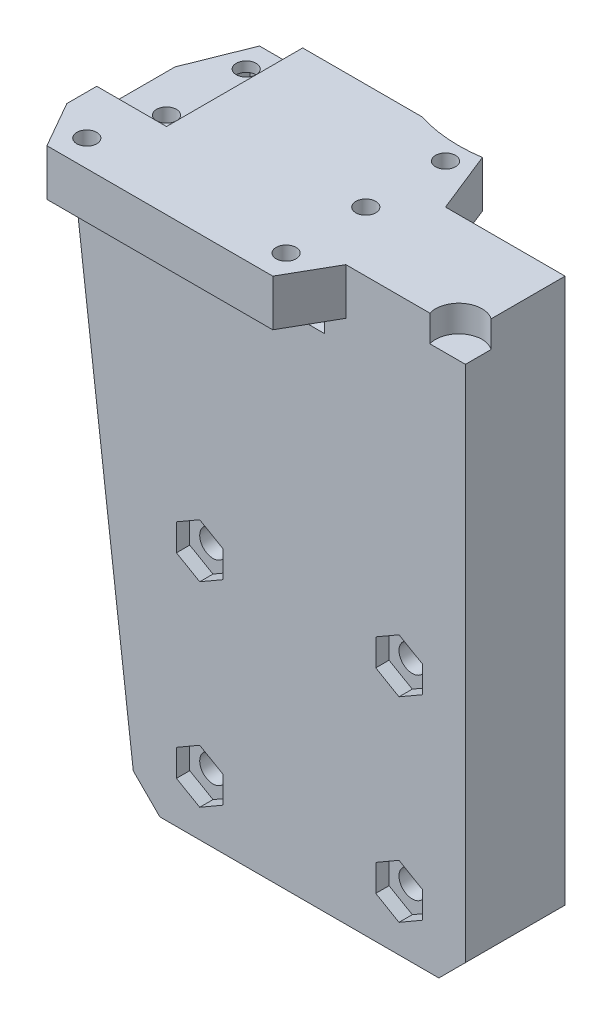
from build123d import *

# Parameters (mm, degrees)
SKETCH1_W               = 50
SKETCH1_H               = 70
BOSS_EXTRUDE1_DEPTH     = 15
SKETCH3_R               = 2
CUT_EXTRUDE1_DEPTH      = 16
SKETCH4_W               = 50
SKETCH4_H               = 15
BOSS_EXTRUDE2_DEPTH     = 16
CHAMFER1_SIZE           = 4
BOSS_EXTRUDE3_DEPTH     = 15
SKETCH6_R               = 3.5
CUT_EXTRUDE2_DEPTH      = 4
SKETCH7_R               = 1.5
BOSS_EXTRUDE4_DEPTH     = 7
CUT_EXTRUDE3_DEPTH      = 8
CUT_EXTRUDE3_DEPTH_BACK = 26
SKETCH7_2_R             = 1.5
CUT_EXTRUDE4_DEPTH      = 20
SKETCH9_W               = 5.6
SKETCH9_H               = 2.6
CUT_EXTRUDE5_DEPTH      = 26
SKETCH10_W              = 10.5
SKETCH10_H              = 20.5
CUT_EXTRUDE6_DEPTH      = 3
CUT_EXTRUDE7_DEPTH      = 2.5
CUT_EXTRUDE8_DEPTH      = 2
SKETCH14_R              = 22
CUT_EXTRUDE9_DEPTH      = 87


with BuildPart() as part:
    # Sketch1 → Boss-Extrude1 (new body)
    with BuildSketch(Plane.XY):
        Rectangle(SKETCH1_W, SKETCH1_H)
    extrude(amount=BOSS_EXTRUDE1_DEPTH)

    # Sketch3 → Cut-Extrude1 (cut, through all)
    with BuildSketch(Plane.XY.offset(15)):
        with Locations((-15, 2.7)):
            Circle(SKETCH3_R)
        with Locations((15, 2.7)):
            Circle(SKETCH3_R)
        with Locations((-15, -26.7)):
            Circle(SKETCH3_R)
        with Locations((15, -26.7)):
            Circle(SKETCH3_R)
    extrude(amount=-CUT_EXTRUDE1_DEPTH, mode=Mode.SUBTRACT)

    # Sketch4 → Boss-Extrude2 (add)
    with BuildSketch(Plane(origin=(0, 35, 0), x_dir=(1, 0, 0), z_dir=(0, 1, 0))):
        with Locations((0, -7.5)):
            Rectangle(SKETCH4_W, SKETCH4_H)
    extrude(amount=BOSS_EXTRUDE2_DEPTH)

    # Chamfer1
    chamfer1_edges = [part.edges().sort_by_distance(p)[0] for p in [
        (25, -35, 7.5),
        (-25, -35, 7.5),
    ]]
    chamfer(chamfer1_edges, length=CHAMFER1_SIZE)

    # Sketch5 → Boss-Extrude3 (add)
    with BuildSketch(Plane.XY.offset(15)):
        Polygon((-25, 51), (-35, 51), (-25, -31), align=None)
    extrude(amount=-BOSS_EXTRUDE3_DEPTH)

    # Sketch6 → Cut-Extrude2 (cut)
    with BuildSketch(Plane(origin=(0, 51, 0), x_dir=(1, 0, 0), z_dir=(0, 1, 0))):
        with Locations((23, -14)):
            Circle(SKETCH6_R)
    extrude(amount=-CUT_EXTRUDE2_DEPTH, mode=Mode.SUBTRACT)

    # Sketch7 → Boss-Extrude4 (add)
    with BuildSketch(Plane(origin=(0, 51, 0), x_dir=(1, 0, 0), z_dir=(0, 1, 0))):
        with Locations((-29, -6)):
            Circle(SKETCH7_R)
        with Locations((1, -6)):
            Circle(SKETCH7_R)
        Polygon((-35, -15), (-31, -22), (3, -22), (7, -15), align=None)
        with Locations((-29, -18)):
            Circle(SKETCH7_R, mode=Mode.SUBTRACT)
        with Locations((1, -18)):
            Circle(SKETCH7_R, mode=Mode.SUBTRACT)
        Polygon((-35, 0), (-31, 10), (3, 10), (7, 0), align=None)
        with Locations((-29, 6)):
            Circle(SKETCH7_R, mode=Mode.SUBTRACT)
        with Locations((1, 6)):
            Circle(SKETCH7_R, mode=Mode.SUBTRACT)
    extrude(amount=-BOSS_EXTRUDE4_DEPTH)

    # Sketch8 → Cut-Extrude3 (cut, two sides)
    with BuildSketch(Plane.XY.offset(15)) as cut_extrude3_sk:
        Polygon((-35, 51), (-34.146341463, 44), (-33.909721647, 42.059717507), (-44.503182053, 47.14840404), (-41.913565843, 51), align=None)
    extrude(amount=CUT_EXTRUDE3_DEPTH, mode=Mode.SUBTRACT)
    extrude(cut_extrude3_sk.sketch, amount=-CUT_EXTRUDE3_DEPTH_BACK, mode=Mode.SUBTRACT)

    # Sketch7_2 → Cut-Extrude4 (cut)
    with BuildSketch(Plane(origin=(0, 51, 0), x_dir=(1, 0, 0), z_dir=(0, 1, 0))):
        with Locations((-29, -6)):
            Circle(SKETCH7_2_R)
        with Locations((1, -6)):
            Circle(SKETCH7_2_R)
    extrude(amount=-CUT_EXTRUDE4_DEPTH, mode=Mode.SUBTRACT)

    # Sketch9 → Cut-Extrude5 (cut, through all)
    with BuildSketch(Plane.XY.offset(15)):
        with Locations((-29, 41.7)):
            Rectangle(SKETCH9_W, SKETCH9_H)
        with Locations((1, 41.7)):
            Rectangle(SKETCH9_W, SKETCH9_H)
    extrude(amount=-CUT_EXTRUDE5_DEPTH, mode=Mode.SUBTRACT)

    # Sketch10 → Cut-Extrude6 (cut)
    with BuildSketch(Plane(origin=(0, 51, 0), x_dir=(1, 0, 0), z_dir=(0, 1, 0))):
        with Locations((-29.75, -0.25)):
            Rectangle(SKETCH10_W, SKETCH10_H)
    extrude(amount=-CUT_EXTRUDE6_DEPTH, mode=Mode.SUBTRACT)

    # Sketch11 → Cut-Extrude7 (cut)
    with BuildSketch(Plane.XZ.offset(-44)):
        Polygon((-30.999351715, -8.540851443), (-27.799233961, -9.001915098), (-25.799882246, -6.461063655), (-27.000648285, -3.459148557), (-30.200766039, -2.998084902), (-32.200117754, -5.538936345), align=None)
        Polygon((2.616580754, -8.8), (4.233161507, -6), (2.616580754, -3.2), (-0.616580754, -3.2), (-2.233161507, -6), (-0.616580754, -8.8), align=None)
        Polygon((-32.233129457, 17.985603874), (-30.604097318, 15.192829694), (-27.370967861, 15.207225819), (-25.766870543, 18.014396126), (-27.395902682, 20.807170306), (-30.629032139, 20.792774181), align=None)
        Polygon((2.629032139, 20.792774181), (-0.604097318, 20.807170306), (-2.233129457, 18.014396126), (-0.629032139, 15.207225819), (2.604097318, 15.192829694), (4.233129457, 17.985603874), align=None)
    extrude(amount=-CUT_EXTRUDE7_DEPTH, mode=Mode.SUBTRACT)

    # Sketch13 → Cut-Extrude8 (cut)
    with BuildSketch(Plane.XY.offset(15)):
        Polygon((11.5, 0.679274058), (15, -1.341451884), (18.5, 0.679274058), (18.5, 4.720725942), (15, 6.741451884), (11.5, 4.720725942), align=None)
        Polygon((-18.5, -28.720725942), (-15, -30.741451884), (-11.5, -28.720725942), (-11.5, -24.679274058), (-15, -22.658548116), (-18.5, -24.679274058), align=None)
        Polygon((18.5, -28.720725942), (18.5, -24.679274058), (15, -22.658548116), (11.5, -24.679274058), (11.5, -28.720725942), (15, -30.741451884), align=None)
        Polygon((-11.5, 4.720725942), (-15, 6.741451884), (-18.5, 4.720725942), (-18.5, 0.679274058), (-15, -1.341451884), (-11.5, 0.679274058), align=None)
    extrude(amount=-CUT_EXTRUDE8_DEPTH, mode=Mode.SUBTRACT)

    # Sketch14 → Cut-Extrude9 (cut, through all)
    with BuildSketch(Plane(origin=(0, 51, 0), x_dir=(1, 0, 0), z_dir=(0, 1, 0))):
        with Locations((0, 31)):
            Circle(SKETCH14_R)
    extrude(amount=-CUT_EXTRUDE9_DEPTH, mode=Mode.SUBTRACT)


solid = part.part
